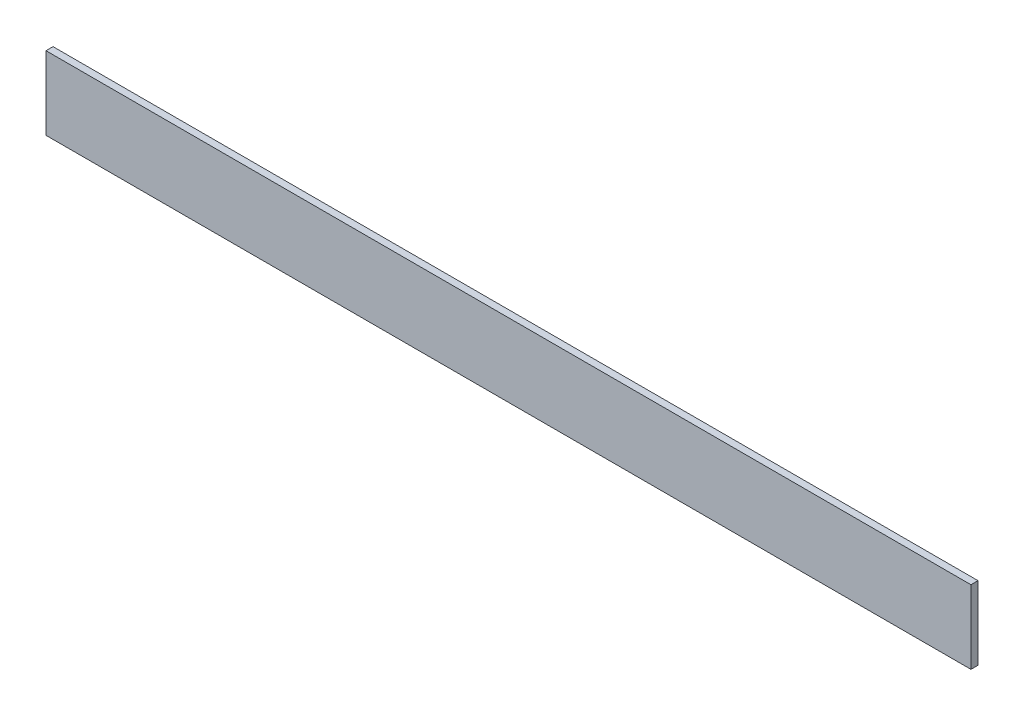
from build123d import *

# Parameters (mm, degrees)
SKETCH1_W           = 416.08
SKETCH1_H           = 32.978461645
BOSS_EXTRUDE1_DEPTH = 3.175


with BuildPart() as part:
    # Sketch1 → Boss-Extrude1 (new body)
    with BuildSketch(Plane.XY):
        with Locations((-13.187058824, 22.224524941)):
            Rectangle(SKETCH1_W, SKETCH1_H)
    extrude(amount=BOSS_EXTRUDE1_DEPTH)


solid = part.part
